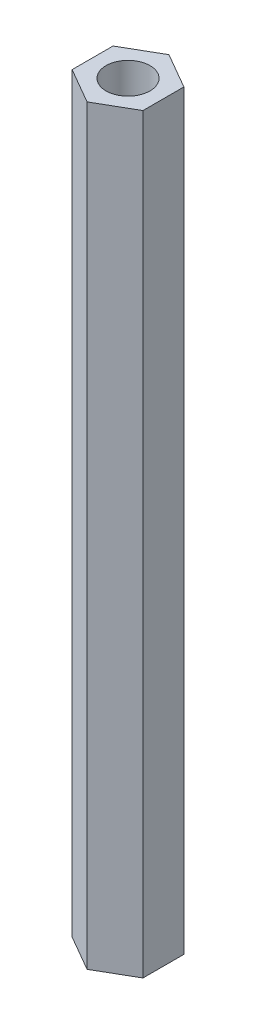
from build123d import *

# Parameters (mm, degrees)
SKETCH_1_R      = 1.55
EXTRUDE_1_DEPTH = 53


with BuildPart() as part:
    # Эскиз1 → Бобышка-Вытянуть1 (new body)
    with BuildSketch(Plane(origin=(0, 0, 0), x_dir=(1, 0, 0), z_dir=(0, 1, 0))):
        Polygon((0, -2.886751346), (2.5, -1.443375673), (2.5, 1.443375673), (0, 2.886751346), (-2.5, 1.443375673), (-2.5, -1.443375673), align=None)
        Circle(SKETCH_1_R, mode=Mode.SUBTRACT)
    extrude(amount=EXTRUDE_1_DEPTH)


solid = part.part
